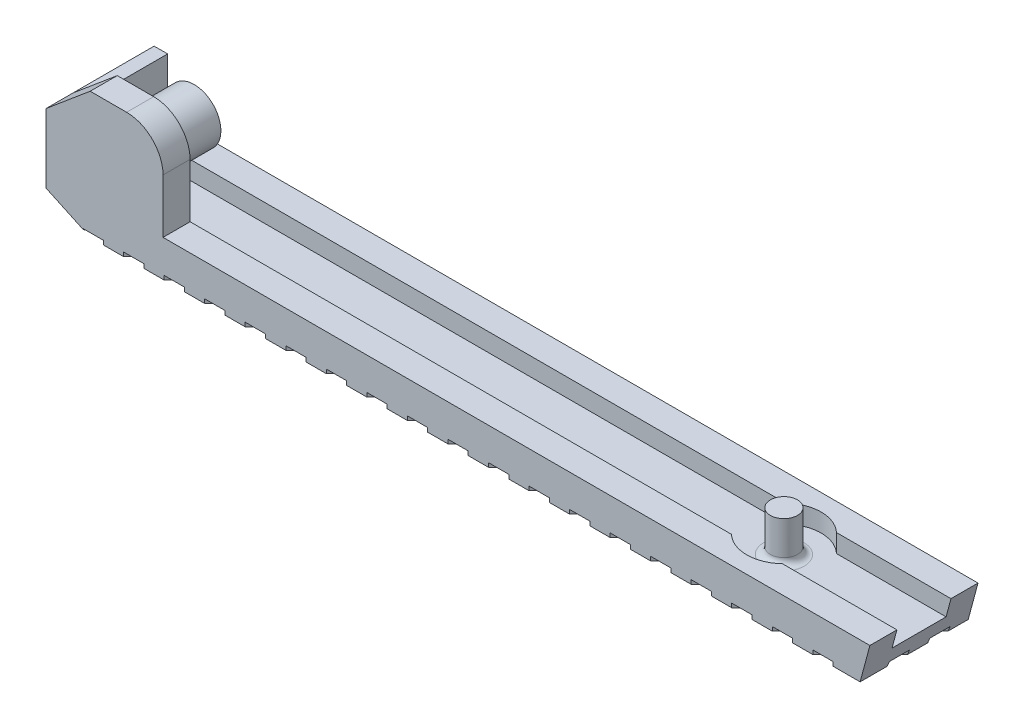
from build123d import *

# Parameters (mm, degrees)
SKETCH1_R           = 1.975
BOSS_EXTRUDE1_DEPTH = 3
SKETCH2_R           = 1
CUT_EXTRUDE1_DEPTH  = 4
BOSS_EXTRUDE3_DEPTH = 2
SKETCH4_W           = 1
SKETCH4_H           = 5.097660252
BOSS_EXTRUDE5_DEPTH = 6
BOSS_EXTRUDE6_DEPTH = 6
BOSS_EXTRUDE7_DEPTH = 2
SKETCH8_R           = 1
BOSS_EXTRUDE8_DEPTH = 3
SKETCH9_R           = 2.75
SKETCH9_R_2         = 1
CUT_EXTRUDE2_DEPTH  = 3
FILLET1_R           = 0.5
CUT_EXTRUDE5_DEPTH  = 0.3


with BuildPart() as part:
    # Sketch1 → Boss-Extrude1 (new body)
    with BuildSketch(Plane.XY):
        Circle(SKETCH1_R)
    extrude(amount=BOSS_EXTRUDE1_DEPTH)

    # Sketch2 → Cut-Extrude1 (cut, through all)
    with BuildSketch(Plane.XY.offset(3)):
        Circle(SKETCH2_R)
    extrude(amount=-CUT_EXTRUDE1_DEPTH, mode=Mode.SUBTRACT)

    # Sketch3 → Boss-Extrude3 (add)
    with BuildSketch(Plane.XY.offset(3)):
        with BuildLine():
            Line((2.696329955, 0.027323162), (2.69646839, -3.972676835))
            Line((2.69646839, -3.972676835), (55, -3.972676835))
            Line((55, -3.972676835), (54.277483472, -6.669145226))
            Line((54.277483472, -6.669145226), (0, -6.669145226))
            Line((0, -6.669145226), (-2.69646839, -6.669145226))
            Line((-2.69646839, -6.669145226), (-5.965910349, -5.144579403))
            Line((-5.965910349, -5.144579403), (-5.965910349, -0.046919151))
            Line((-5.965910349, -0.046919151), (-2.69646839, 2.69646839))
            Line((-2.69646839, 2.69646839), (0, 2.69646839))
            ThreePointArc((0, 2.69646839), (1.897006291, 1.916326932), (2.696329955, 0.027323162))
        make_face()
    extrude(amount=BOSS_EXTRUDE3_DEPTH)

    # Sketch4 → Boss-Extrude5 (add)
    with BuildSketch(Plane(origin=(0, 0, 3), x_dir=(-1, 0, 0), z_dir=(0, 0, -1))):
        with Locations((5.465910349, -2.595749277)):
            Rectangle(SKETCH4_W, SKETCH4_H)
    extrude(amount=BOSS_EXTRUDE5_DEPTH)

    # Sketch5 → Boss-Extrude6 (add)
    with BuildSketch(Plane(origin=(0, 0, 3), x_dir=(-1, 0, 0), z_dir=(0, 0, -1))):
        Polygon((-54.638741736, -5.320911031), (2.690099823, -5.320911031), (4.965910349, -4.259683154), (4.965910349, -5.144579403), (5.965910349, -5.144579403), (2.69646839, -6.669145226), (-54.277483472, -6.669145226), align=None)
    extrude(amount=BOSS_EXTRUDE6_DEPTH)

    # Sketch6 → Boss-Extrude7 (add)
    with BuildSketch(Plane(origin=(0, 0, -3), x_dir=(-1, 0, 0), z_dir=(0, 0, -1))):
        Polygon((-54.638741736, -5.320911031), (-55, -3.972676835), (2.620283863, -3.972676835), (4.965910349, -2.878893242), (4.965910349, -4.259683154), (2.690099823, -5.320911031), align=None)
    extrude(amount=-BOSS_EXTRUDE7_DEPTH)

    # Sketch8 → Boss-Extrude8 (add)
    with BuildSketch(Plane(origin=(0, -5.320911031, 0), x_dir=(1, 0, 0), z_dir=(0, 1, 0))):
        with Locations((44.638741736, -1)):
            Circle(SKETCH8_R)
    extrude(amount=BOSS_EXTRUDE8_DEPTH)

    # Sketch9 → Cut-Extrude2 (cut)
    with BuildSketch(Plane(origin=(0, -5.320911031, 0), x_dir=(1, 0, 0), z_dir=(0, 1, 0))):
        with Locations((44.638741736, -1)):
            Circle(SKETCH9_R)
        with Locations((44.638741736, -1)):
            Circle(SKETCH9_R_2, mode=Mode.SUBTRACT)
    extrude(amount=CUT_EXTRUDE2_DEPTH, mode=Mode.SUBTRACT)

    # Fillet1
    fillet1_edges = [part.edges().sort_by_distance(p)[0] for p in [
        (43.638741736, -5.320911031, 1),
    ]]
    fillet(fillet1_edges, radius=FILLET1_R)

    # Sketch10 → Cut-Extrude5 (cut)
    with BuildSketch(Plane.XZ.offset(6.669145226)):
        Polygon((54.277483472, -3), (46.277483472, 5), (44.777483472, 5), (52.777483472, -3), align=None)
        Polygon((49.777483472, -3), (51.277483472, -3), (43.277483472, 5), (41.777483472, 5), align=None)
        Polygon((46.777483472, -3), (48.277483472, -3), (40.277483472, 5), (38.777483472, 5), align=None)
        Polygon((43.777483472, -3), (45.277483472, -3), (37.277483472, 5), (35.777483472, 5), align=None)
        Polygon((40.777483472, -3), (42.277483472, -3), (34.277483472, 5), (32.777483472, 5), align=None)
        Polygon((37.777483472, -3), (39.277483472, -3), (31.277483472, 5), (29.777483472, 5), align=None)
        Polygon((34.777483472, -3), (36.277483472, -3), (28.277483472, 5), (26.777483472, 5), align=None)
        Polygon((31.777483472, -3), (33.277483472, -3), (25.277483472, 5), (23.777483472, 5), align=None)
        Polygon((28.777483472, -3), (30.277483472, -3), (22.277483472, 5), (20.777483472, 5), align=None)
        Polygon((25.777483472, -3), (27.277483472, -3), (19.277483472, 5), (17.777483472, 5), align=None)
        Polygon((22.777483472, -3), (24.277483472, -3), (16.277483472, 5), (14.777483472, 5), align=None)
        Polygon((19.777483472, -3), (21.277483472, -3), (13.277483472, 5), (11.777483472, 5), align=None)
        Polygon((16.777483472, -3), (18.277483472, -3), (10.277483472, 5), (8.777483472, 5), align=None)
        Polygon((13.777483472, -3), (15.277483472, -3), (7.277483472, 5), (5.777483472, 5), align=None)
        Polygon((10.777483472, -3), (12.277483472, -3), (4.277483472, 5), (2.777483472, 5), align=None)
        Polygon((7.777483472, -3), (9.277483472, -3), (1.277483472, 5), (-0.222516528, 5), align=None)
        Polygon((4.777483472, -3), (6.277483472, -3), (-1.722516528, 5), (-3.222516528, 5), align=None)
        Polygon((1.777483472, -3), (3.277483472, -3), (-4.722516528, 5), (-6.222516528, 5), align=None)
        Polygon((-1.222516528, -3), (0.277483472, -3), (-7.722516528, 5), (-9.222516528, 5), align=None)
        Polygon((55.777483472, -3), (57.277483472, -3), (49.277483472, 5), (47.777483472, 5), align=None)
        Polygon((58.777483472, -3), (60.277483472, -3), (52.277483472, 5), (50.777483472, 5), align=None)
    extrude(amount=-CUT_EXTRUDE5_DEPTH, mode=Mode.SUBTRACT)


solid = part.part
